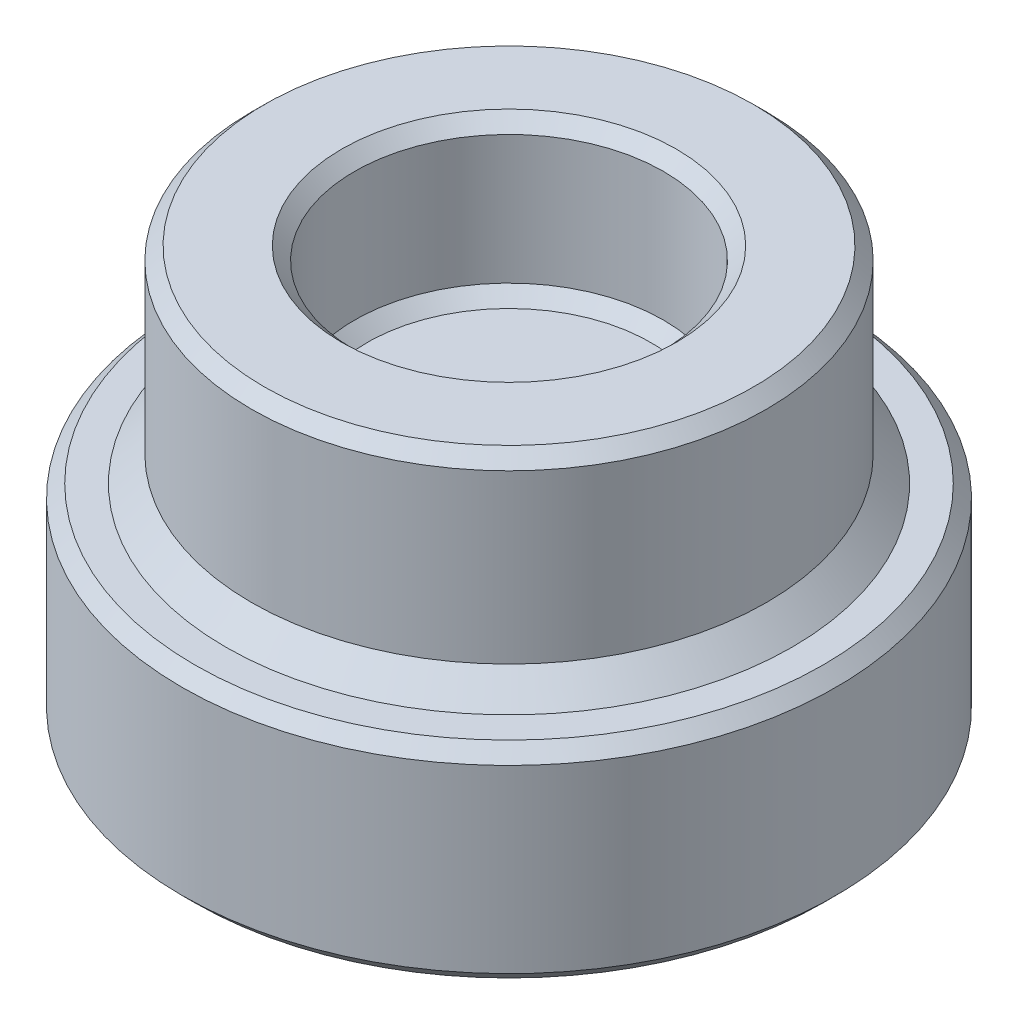
from build123d import *

# Parameters (mm, degrees)
SKETCH1_R                       = 5
BOSS_EXTRUDE1_DEPTH             = 1
SKETCH1_3_R                     = 5
SKETCH1_3_R_2                   = 3
BOSS_EXTRUDE2_DEPTH             = 4
CHAMFER1_SIZE                   = 0.25
SKETCH5_R                       = 6.35
BOSS_EXTRUDE4_DEPTH             = 4
F_6_0MM_DOWEL_HOLE1_D           = 6
F_6_0MM_DOWEL_HOLE1_DEPTH       = 3.737534009
F_6_0MM_DOWEL_HOLE1_CSINK_D     = 6.25
F_6_0MM_DOWEL_HOLE1_CSINK_ANGLE = 90
F_6_0MM_DOWEL_HOLE1_TIP         = 0.262465991
CHAMFER2_SIZE                   = 0.25
CHAMFER3_SIZE                   = 0.5


with BuildPart() as part:
    # Sketch1 → Boss-Extrude1 (new body)
    with BuildSketch(Plane(origin=(0, 0, 0), x_dir=(1, 0, 0), z_dir=(0, 1, 0))):
        Circle(SKETCH1_R)
    extrude(amount=BOSS_EXTRUDE1_DEPTH)

    # Sketch1_3 → Boss-Extrude2 (add)
    with BuildSketch(Plane(origin=(0, 0, 0), x_dir=(1, 0, 0), z_dir=(0, 1, 0))):
        Circle(SKETCH1_3_R)
        Circle(SKETCH1_3_R_2, mode=Mode.SUBTRACT)
    extrude(amount=BOSS_EXTRUDE2_DEPTH)

    # Chamfer1
    chamfer1_edges = [part.edges().sort_by_distance(p)[0] for p in [
        (-3, 4, 0),
        (-5, 4, 0),
        (-3, 1, 0),
    ]]
    chamfer(chamfer1_edges, length=CHAMFER1_SIZE)

    # Sketch5 → Boss-Extrude4 (add)
    with BuildSketch(Plane(origin=(0, 0, 0), x_dir=(1, 0, 0), z_dir=(0, 1, 0))):
        Circle(SKETCH5_R)
    extrude(amount=-BOSS_EXTRUDE4_DEPTH)

    # Ø6.0mm Dowel Hole1
    with Locations(Plane(origin=(0, -4, 0), x_dir=(-1, 0, 0), z_dir=(0, -1, 0))):
        with Locations((0, 0)):
            CounterSinkHole(F_6_0MM_DOWEL_HOLE1_D / 2, F_6_0MM_DOWEL_HOLE1_CSINK_D / 2, depth=F_6_0MM_DOWEL_HOLE1_DEPTH, counter_sink_angle=F_6_0MM_DOWEL_HOLE1_CSINK_ANGLE)
            with Locations((0, 0, -(F_6_0MM_DOWEL_HOLE1_DEPTH + F_6_0MM_DOWEL_HOLE1_TIP / 2))):  # 170° drill point
                Cone(0, F_6_0MM_DOWEL_HOLE1_D / 2, F_6_0MM_DOWEL_HOLE1_TIP, mode=Mode.SUBTRACT)

    # Chamfer2
    chamfer2_edges = [part.edges().sort_by_distance(p)[0] for p in [
        (-6.35, -4, 0),
        (-6.35, 0, 0),
    ]]
    chamfer(chamfer2_edges, length=CHAMFER2_SIZE)

    # Chamfer3
    chamfer3_edges = [part.edges().sort_by_distance(p)[0] for p in [
        (-5, 0, 0),
    ]]
    chamfer(chamfer3_edges, length=CHAMFER3_SIZE)


solid = part.part
